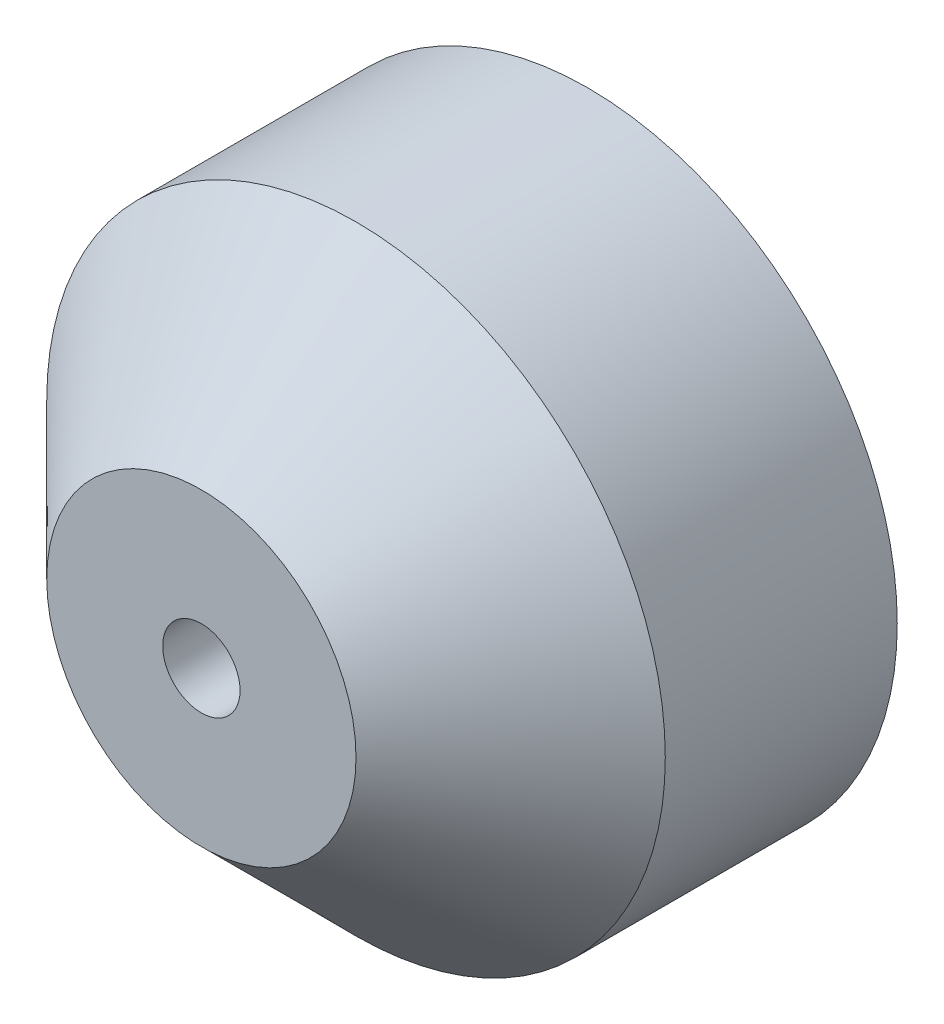
from build123d import *

# Parameters (mm, degrees)
SKETCH1_R           = 20
BOSS_EXTRUDE1_DEPTH = 25
CHAMFER1_SIZE       = 10
SKETCH2_R           = 2.5
CUT_EXTRUDE1_DEPTH  = 15
SKETCH3_R           = 7.5
BOSS_EXTRUDE2_DEPTH = 7


with BuildPart() as part:
    # Sketch1 → Boss-Extrude1 (new body)
    with BuildSketch(Plane.XY):
        Circle(SKETCH1_R)
    extrude(amount=BOSS_EXTRUDE1_DEPTH)

    # Chamfer1
    chamfer1_edges = [part.edges().sort_by_distance(p)[0] for p in [
        (-20, 0, 25),
    ]]
    chamfer(chamfer1_edges, length=CHAMFER1_SIZE)

    # Sketch2 → Cut-Extrude1 (cut)
    with BuildSketch(Plane.XY.offset(25)):
        Circle(SKETCH2_R)
    extrude(amount=-CUT_EXTRUDE1_DEPTH, mode=Mode.SUBTRACT)

    # Sketch3 → Boss-Extrude2 (add)
    with BuildSketch(Plane(origin=(0, 0, 0), x_dir=(-1, 0, 0), z_dir=(0, 0, -1))):
        Circle(SKETCH3_R)
    extrude(amount=BOSS_EXTRUDE2_DEPTH)


solid = part.part
